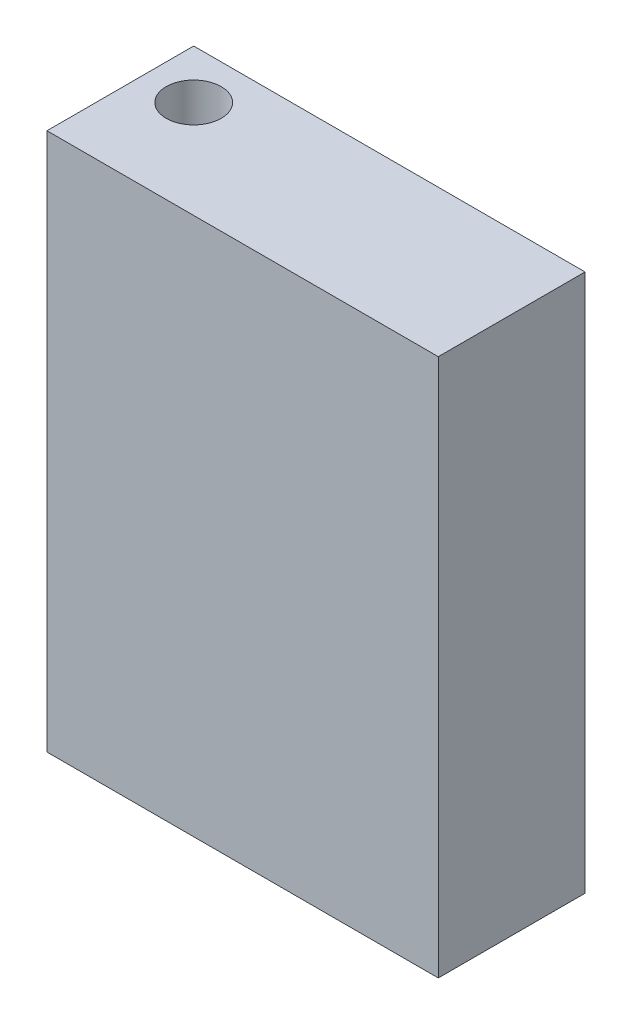
from build123d import *

# Parameters (mm, degrees)
SKETCH1_W           = 50.8
SKETCH1_H           = 69.85
BOSS_EXTRUDE1_DEPTH = 19.05
SKETCH2_R           = 3.571875
CUT_EXTRUDE1_DEPTH  = 70.85


with BuildPart() as part:
    # Sketch1 → Boss-Extrude1 (new body)
    with BuildSketch(Plane.XY):
        with Locations((25.4, 34.925)):
            Rectangle(SKETCH1_W, SKETCH1_H)
    extrude(amount=BOSS_EXTRUDE1_DEPTH)

    # Sketch2 → Cut-Extrude1 (cut, through all)
    with BuildSketch(Plane(origin=(0, 69.85, 0), x_dir=(1, 0, 0), z_dir=(0, 1, 0))):
        with Locations((6.35, -6.35)):
            Circle(SKETCH2_R)
    extrude(amount=-CUT_EXTRUDE1_DEPTH, mode=Mode.SUBTRACT)


solid = part.part
